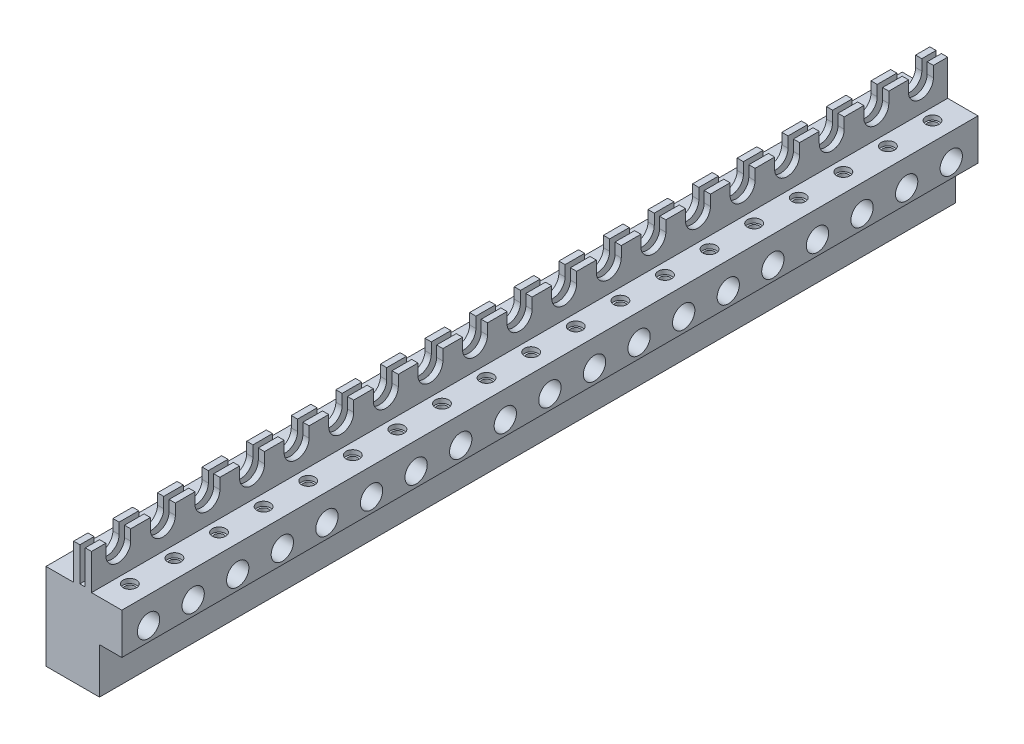
from build123d import *

# Parameters (mm, degrees)
SKETCH1_W                    = 8.5
SKETCH1_H                    = 13.7
BOSS_EXTRUDE1_DEPTH          = 96
SKETCH2_W                    = 2.5
SKETCH2_H                    = 5.1
CUT_EXTRUDE1_DEPTH           = 97.337868982
SKETCH3_W                    = 3.1
SKETCH3_H                    = 4
SKETCH3_W_2                  = 3.4
SKETCH3_W_3                  = 0.6
SKETCH3_H_2                  = 3.8
CUT_EXTRUDE2_DEPTH           = 97.337868982
CUT_EXTRUDE3_DEPTH           = 97.379108213
LPATTERN1_COUNT              = 19
LPATTERN1_PITCH              = 5
SKETCH5_R                    = 1.25
CUT_EXTRUDE4_DEPTH           = 97.618696431
LPATTERN2_COUNT              = 19
LPATTERN2_PITCH              = 5
LPATTERN3_COUNT              = 19
LPATTERN3_PITCH              = 5
M1_4X0_3_TAPPED_HOLE1_REACH  = 98.582
M1_4X0_3_TAPPED_HOLE1_BORE_R = 0.55
SKETCH14_R                   = 0.75
CUT_EXTRUDE5_DEPTH           = 0.5
LPATTERN4_COUNT              = 19
LPATTERN4_PITCH              = 5


with BuildPart() as part:
    # Sketch1 → Boss-Extrude1 (new body)
    with BuildSketch(Plane.XY):
        Rectangle(SKETCH1_W, SKETCH1_H)
    extrude(amount=-BOSS_EXTRUDE1_DEPTH)

    # Sketch2 → Cut-Extrude1 (cut, through all)
    with BuildSketch(Plane.XY):
        with Locations((3, -4.3)):
            Rectangle(SKETCH2_W, SKETCH2_H)
    extrude(amount=-CUT_EXTRUDE1_DEPTH, mode=Mode.SUBTRACT)

    # Sketch3 → Cut-Extrude2 (cut, through all)
    with BuildSketch(Plane.XY):
        with Locations((-2.7, 4.85)):
            Rectangle(SKETCH3_W, SKETCH3_H)
        with Locations((2.55, 4.85)):
            Rectangle(SKETCH3_W_2, SKETCH3_H)
        with Locations((-0.15, 4.95)):
            Rectangle(SKETCH3_W_3, SKETCH3_H_2)
    extrude(amount=-CUT_EXTRUDE2_DEPTH, mode=Mode.SUBTRACT)

    # Sketch4 → Cut-Extrude3 (cut, through all)
    with BuildSketch(Plane(origin=(0.85, 0, 0), x_dir=(0, 0, -1), z_dir=(1, 0, 0))):
        with BuildLine():
            Line((1.6, 6.85), (1.6, 5.65))
            ThreePointArc((1.6, 5.65), (3, 4.25), (4.4, 5.65))
            Line((4.4, 5.65), (4.4, 6.85))
            Line((4.4, 6.85), (1.6, 6.85))
        make_face()
    cut_extrude3 = extrude(amount=-CUT_EXTRUDE3_DEPTH, mode=Mode.SUBTRACT)

    # LPattern1: Cut-Extrude3 ×19
    with Locations(*[(0, 0, -i * LPATTERN1_PITCH) for i in range(1, LPATTERN1_COUNT)]):
        add(cut_extrude3, mode=Mode.SUBTRACT)

    # Sketch5 → Cut-Extrude4 (cut, through all)
    with BuildSketch(Plane(origin=(4.25, 0, 0), x_dir=(0, 0, -1), z_dir=(1, 0, 0))):
        with Locations((3, -0.15)):
            Circle(SKETCH5_R)
    cut_extrude4 = extrude(amount=-CUT_EXTRUDE4_DEPTH, mode=Mode.SUBTRACT)

    # LPattern2: Cut-Extrude4 ×19
    with Locations(*[(0, 0, -i * LPATTERN2_PITCH) for i in range(1, LPATTERN2_COUNT)]):
        add(cut_extrude4, mode=Mode.SUBTRACT)

    # Sketch10 → Ø1.8 (1.8) Diameter Hole1 (revolve, cut)
    with BuildSketch(Plane(origin=(-2.85, 2.85, -3), x_dir=(0, 0, 1), z_dir=(1, 0, 0))):
        Polygon((0, 0), (0, 8.455189668), (0.9, 7.7), (0.9, 0), align=None)
    f_1_8_1_8_diameter_hole1 = revolve(axis=Axis((-2.85, 9.2, -3), (0, -1, 0)), mode=Mode.SUBTRACT)

    # LPattern3: Ø1.8 (1.8) Diameter Hole1 ×19
    with Locations(*[(0, 0, -i * LPATTERN3_PITCH) for i in range(1, LPATTERN3_COUNT)]):
        add(f_1_8_1_8_diameter_hole1, mode=Mode.SUBTRACT)

    # M1.4x0.3 Tapped Hole1 bore → M1.4x0.3 Tapped Hole1 (cut, up to next)
    with BuildSketch(Plane(origin=(0, 2.85, 0), x_dir=(-1, 0, 0), z_dir=(0, 1, 0)), mode=Mode.PRIVATE) as m1_4x0_3_tapped_hole1_sk1:
        with Locations((-2.15, -3)):
            Circle(M1_4X0_3_TAPPED_HOLE1_BORE_R)
    m1_4x0_3_tapped_hole1_tool1 = extrude(m1_4x0_3_tapped_hole1_sk1.sketch, amount=-M1_4X0_3_TAPPED_HOLE1_REACH, mode=Mode.PRIVATE) & part.part
    m1_4x0_3_tapped_hole1 = m1_4x0_3_tapped_hole1_tool1.solids().sort_by_distance((2.15, 2.85, -3))[0]
    add(m1_4x0_3_tapped_hole1, mode=Mode.SUBTRACT)

    # Sketch14 → Cut-Extrude5 (cut)
    with BuildSketch(Plane(origin=(0, 2.85, 0), x_dir=(1, 0, 0), z_dir=(0, 1, 0))):
        with Locations(Location((2.15, 3, 0), (0, 0, 270))):
            Circle(SKETCH14_R)
    cut_extrude5 = extrude(amount=-CUT_EXTRUDE5_DEPTH, mode=Mode.SUBTRACT)

    # LPattern4: M1.4x0.3 Tapped Hole1, Cut-Extrude5 ×19
    with Locations(*[(0, 0, -i * LPATTERN4_PITCH) for i in range(1, LPATTERN4_COUNT)]):
        add(m1_4x0_3_tapped_hole1, mode=Mode.SUBTRACT)
        add(cut_extrude5, mode=Mode.SUBTRACT)


solid = part.part
